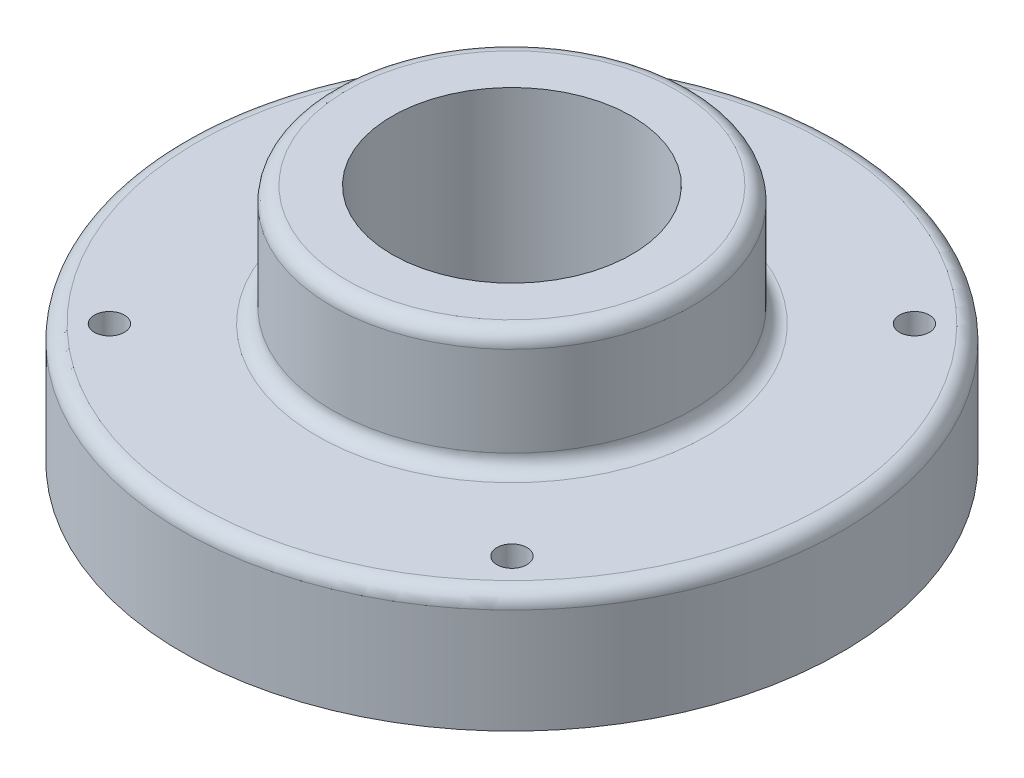
from build123d import *

# Parameters (mm, degrees)
SKETCH2_R          = 1.5875
CUT_EXTRUDE1_DEPTH = 13.7


with BuildPart() as part:
    # Sketch1 → Revolve1 (revolve)
    with BuildSketch(Plane.XY):
        with BuildLine():
            Line((12.7, 25.4), (17.4625, 25.4))
            ThreePointArc((17.4625, 25.4), (18.585032015, 24.935032015), (19.05, 23.8125))
            Line((19.05, 23.8125), (19.05, 14.2875))
            ThreePointArc((19.05, 14.2875), (19.514967985, 13.164967985), (20.6375, 12.7))
            Line((20.6375, 12.7), (33.3375, 12.7))
            ThreePointArc((33.3375, 12.7), (34.460032015, 12.235032015), (34.925, 11.1125))
            Line((34.925, 11.1125), (34.925, 0))
            Line((34.925, 0), (25.4, 0))
            Line((25.4, 0), (25.4, 3.175))
            ThreePointArc((25.4, 3.175), (24.47006403, 5.42006403), (22.225, 6.35))
            Line((22.225, 6.35), (12.7, 6.35))
            Line((12.7, 6.35), (12.7, 25.4))
        make_face()
    revolve(axis=Axis((0, 0, 0), (0, 1, 0)))

    # Sketch2 → Cut-Extrude1 (cut, through all)
    with BuildSketch(Plane(origin=(0, 12.7, 0), x_dir=(1, 0, 0), z_dir=(0, 1, 0))):
        with Locations((-21.328108288, 21.328108288)):
            Circle(SKETCH2_R)
        with Locations((21.328108288, 21.328108288)):
            Circle(SKETCH2_R)
        with Locations((21.328108288, -21.328108288)):
            Circle(SKETCH2_R)
        with Locations((-21.328108288, -21.328108288)):
            Circle(SKETCH2_R)
    extrude(amount=-CUT_EXTRUDE1_DEPTH, mode=Mode.SUBTRACT)


solid = part.part
